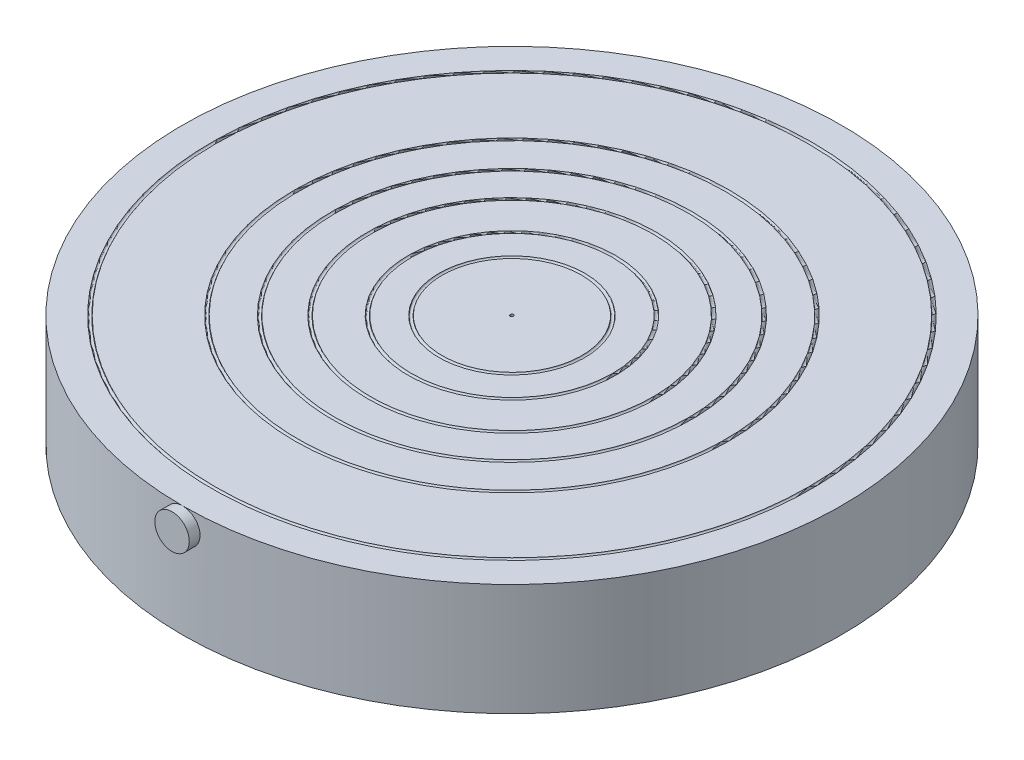
from build123d import *

# Parameters (mm, degrees)
SKETCH1_R           = 101.6
EXTRUDE1_DEPTH      = 34.5
SKETCH4_R           = 0.5
EXTRUDE2_DEPTH      = 1
EXTRUDE3_REACH      = 208.38
EXTRUDE3_END_RADIUS = 101.6
SKETCH5_R           = 5.315


with BuildPart() as part:
    # Sketch1 → Extrude1 (new body)
    with BuildSketch(Plane(origin=(0, 0, 0), x_dir=(1, 0, 0), z_dir=(0, 1, 0))):
        with Locations(Location((0, 0, 0), (0, 0, 270))):  # turned: the seam where the file's is
            Circle(SKETCH1_R)
    extrude(amount=EXTRUDE1_DEPTH)

    # Sketch3 → Cut-Revolve1 (revolve, cut)
    with BuildSketch(Plane.XY, mode=Mode.PRIVATE) as cut_revolve1_sk:
        with BuildLine():
            Line((0, 34.5), (21.5, 34.5))
            ThreePointArc((21.5, 34.5), (22, 34), (22.5, 34.5))
            Line((22.5, 34.5), (31, 34.5))
            ThreePointArc((31, 34.5), (31.5, 34), (32, 34.5))
            Line((32, 34.5), (43.5, 34.5))
            ThreePointArc((43.5, 34.5), (44, 34), (44.5, 34.5))
            Line((44.5, 34.5), (54.5, 34.5))
            ThreePointArc((54.5, 34.5), (55, 34), (55.5, 34.5))
            Line((55.5, 34.5), (66, 34.5))
            ThreePointArc((66, 34.5), (66.5, 34), (67, 34.5))
            Line((67, 34.5), (91.5, 34.5))
            ThreePointArc((91.5, 34.5), (92, 34), (92.5, 34.5))
            Line((92.5, 34.5), (101.6, 34.5))
            Line((101.6, 34.5), (101.6, 39.5))
            Line((101.6, 39.5), (0, 39.5))
            Line((0, 39.5), (0, 34.5))
        make_face()
    revolve(cut_revolve1_sk.sketch.rotate(Axis((0, 0, 0), (0, 1, 0)), 90), axis=Axis((0, 0, 0), (0, 1, 0)), mode=Mode.SUBTRACT)  # turned: the seam where the file's is

    # Sketch4 → Extrude2 (cut)
    with BuildSketch(Plane(origin=(0, 34.5, 0), x_dir=(1, 0, 0), z_dir=(0, 1, 0))):
        with Locations(Location((0, 0, 0), (0, 0, 270))):  # turned: the seam where the file's is
            Circle(SKETCH4_R)
    extrude(amount=-EXTRUDE2_DEPTH, mode=Mode.SUBTRACT)

    # Extrude3: up to this cylinder (the profile starts outside it)
    extrude3_end = Plane(origin=(0, 29.185, 0), z_dir=(0, -1, 0)) * Cylinder(EXTRUDE3_END_RADIUS, 620.96, mode=Mode.PRIVATE)
    # Sketch5 → Extrude3 (add, up to the surface)
    with BuildSketch(Plane.XY.offset(104.78), mode=Mode.PRIVATE) as extrude3_sk1:
        with Locations((0, 29.185)):
            Circle(SKETCH5_R)
    extrude3_tool1 = extrude(extrude3_sk1.sketch, amount=-EXTRUDE3_REACH, mode=Mode.PRIVATE) - extrude3_end
    add(extrude3_tool1.solids().sort_by_distance((0, 29.185, 104.78))[0])


solid = part.part
